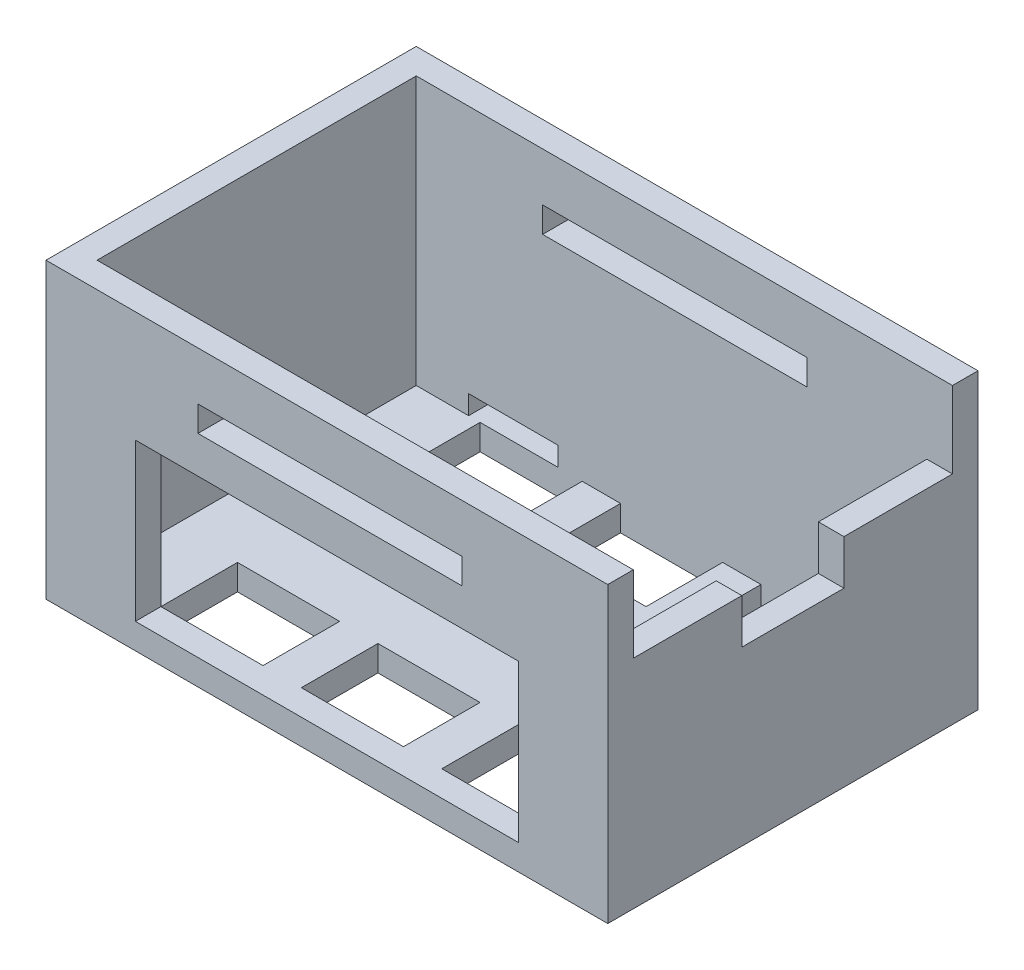
from build123d import *

# Parameters (mm, degrees)
SKETCH2_W           = 44
SKETCH2_H           = 29
BOSS_EXTRUDE1_DEPTH = 23
SKETCH3_W           = 40
SKETCH3_H           = 25
CUT_EXTRUDE1_DEPTH  = 21
SKETCH4_W           = 20.7
SKETCH4_H           = 2
CUT_EXTRUDE2_DEPTH  = 33
SKETCH5_W           = 30
SKETCH5_H           = 12.3
CUT_EXTRUDE3_DEPTH  = 2
CUT_EXTRUDE5_DEPTH  = 2
SKETCH11_W          = 3.9
SKETCH11_H          = 8.6
SKETCH11_W_2        = 7
SKETCH11_H_2        = 1.5
CUT_EXTRUDE6_DEPTH  = 2
SKETCH13_W          = 8
SKETCH13_H          = 6
CUT_EXTRUDE8_DEPTH  = 2


with BuildPart() as part:
    # Sketch2 → Boss-Extrude1 (new body)
    with BuildSketch(Plane(origin=(0, 0, 0), x_dir=(1, 0, 0), z_dir=(0, 1, 0))):
        Rectangle(SKETCH2_W, SKETCH2_H)
    extrude(amount=BOSS_EXTRUDE1_DEPTH)

    # Sketch3 → Cut-Extrude1 (cut)
    with BuildSketch(Plane(origin=(0, 23, 0), x_dir=(1, 0, 0), z_dir=(0, 1, 0))):
        Rectangle(SKETCH3_W, SKETCH3_H)
    extrude(amount=-CUT_EXTRUDE1_DEPTH, mode=Mode.SUBTRACT)

    # Sketch4 → Cut-Extrude2 (cut)
    with BuildSketch(Plane.XY.offset(14.5)):
        with Locations((0.25, 18.2)):
            Rectangle(SKETCH4_W, SKETCH4_H)
    extrude(amount=-CUT_EXTRUDE2_DEPTH, mode=Mode.SUBTRACT)

    # Sketch5 → Cut-Extrude3 (cut)
    with BuildSketch(Plane.XY.offset(14.5)):
        with Locations((0, 8.15)):
            Rectangle(SKETCH5_W, SKETCH5_H)
    extrude(amount=-CUT_EXTRUDE3_DEPTH, mode=Mode.SUBTRACT)

    # Sketch8 → Cut-Extrude5 (cut)
    with BuildSketch(Plane(origin=(22, 0, 0), x_dir=(0, 0, -1), z_dir=(1, 0, 0))):
        Polygon((-12.5, 17), (-4, 17), (-4, 13.5), (4, 13.5), (4, 17), (12.5, 17), (12.5, 23), (-12.5, 23), align=None)
    extrude(amount=-CUT_EXTRUDE5_DEPTH, mode=Mode.SUBTRACT)

    # Sketch11 → Cut-Extrude6 (cut)
    with BuildSketch(Plane(origin=(0, 0, -14.5), x_dir=(-1, 0, 0), z_dir=(0, 0, -1))):
        with Locations((-18.05, 6.3)):
            Rectangle(SKETCH11_W, SKETCH11_H)
        with Locations((12.4, 2.75)):
            Rectangle(SKETCH11_W_2, SKETCH11_H_2)
    extrude(amount=-CUT_EXTRUDE6_DEPTH, mode=Mode.SUBTRACT)

    # Sketch13 → Cut-Extrude8 (cut)
    with BuildSketch(Plane(origin=(0, 2, 0), x_dir=(1, 0, 0), z_dir=(0, 1, 0))):
        with Locations((-11, -9.5)):
            Rectangle(SKETCH13_W, SKETCH13_H)
        with Locations((0, -9.5)):
            Rectangle(SKETCH13_W, SKETCH13_H)
        with Locations((11, 9.5)):
            Rectangle(SKETCH13_W, SKETCH13_H)
        with Locations((11, -9.5)):
            Rectangle(SKETCH13_W, SKETCH13_H)
        with Locations((-11, 9.5)):
            Rectangle(SKETCH13_W, SKETCH13_H)
        with Locations((0, 9.5)):
            Rectangle(SKETCH13_W, SKETCH13_H)
    extrude(amount=-CUT_EXTRUDE8_DEPTH, mode=Mode.SUBTRACT)


solid = part.part
